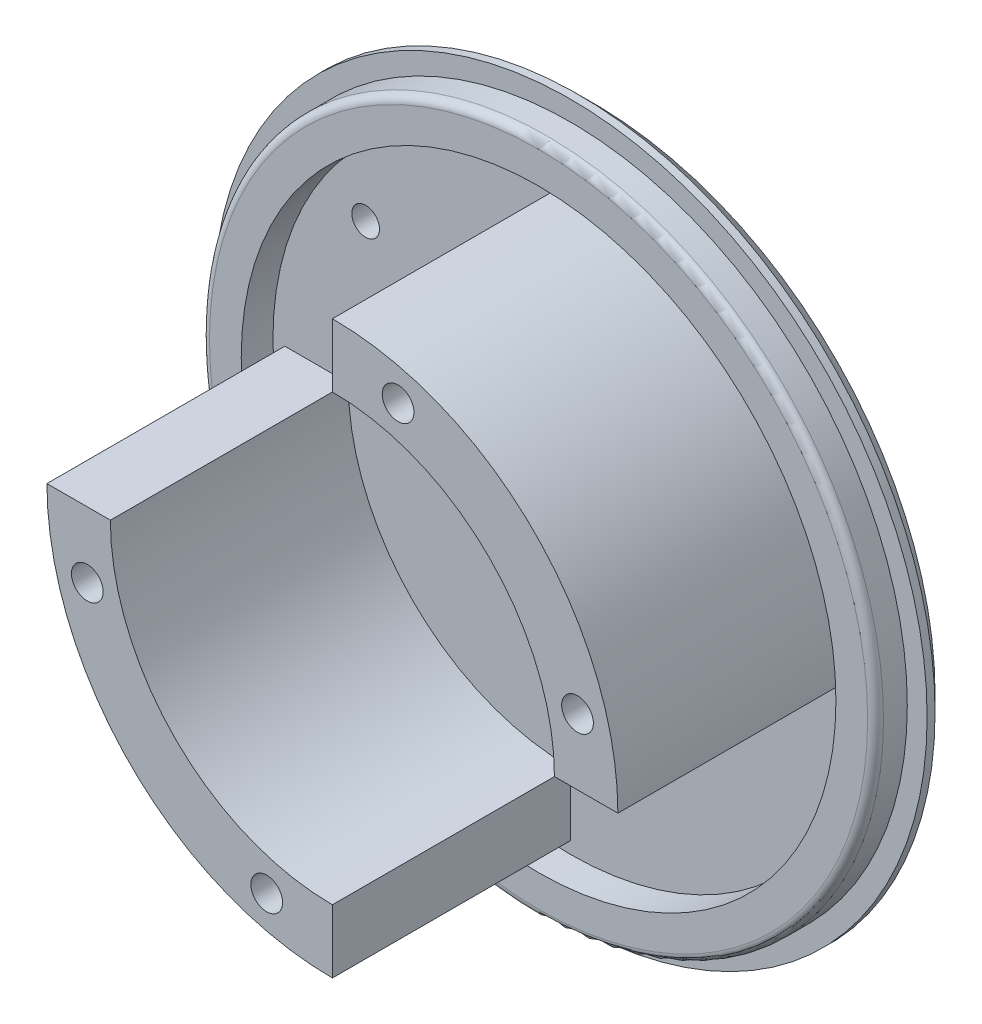
from build123d import *

# Parameters (mm, degrees)
SKETCH1_R           = 45
BOSS_EXTRUDE1_DEPTH = 3
SKETCH2_R           = 42.5
SKETCH2_R_2         = 37.5
BOSS_EXTRUDE2_DEPTH = 4
CHAMFER1_SIZE       = 2
FILLET1_R           = 1
BOSS_EXTRUDE3_DEPTH = 30
SKETCH4_R           = 2
CUT_EXTRUDE1_DEPTH  = 15
CIRPATTERN1_COUNT   = 2
SKETCH5_R           = 1.75
CUT_EXTRUDE2_DEPTH  = 4


with BuildPart() as part:
    # Sketch1 → Boss-Extrude1 (new body)
    with BuildSketch(Plane.XY):
        Circle(SKETCH1_R)
    extrude(amount=BOSS_EXTRUDE1_DEPTH)

    # Sketch2 → Boss-Extrude2 (add)
    with BuildSketch(Plane.XY.offset(3)):
        Circle(SKETCH2_R)
        Circle(SKETCH2_R_2, mode=Mode.SUBTRACT)
    extrude(amount=BOSS_EXTRUDE2_DEPTH)

    # Chamfer1
    chamfer1_edges = [part.edges().sort_by_distance(p)[0] for p in [
        (-45, 0, 0),
    ]]
    chamfer(chamfer1_edges, length=CHAMFER1_SIZE)

    # Fillet1
    fillet1_edges = [part.edges().sort_by_distance(p)[0] for p in [
        (-42.5, 0, 7),
    ]]
    fillet(fillet1_edges, radius=FILLET1_R)

    # Sketch3 → Boss-Extrude3 (add)
    with BuildSketch(Plane.XY.offset(3)):
        with BuildLine():
            Line((-36, 0), (-28, 0))
            ThreePointArc((-28, 0), (-19.798989873, -19.798989873), (0, -28))
            Line((0, -28), (0, -36))
            ThreePointArc((0, -36), (-25.455844123, -25.455844123), (-36, 0))
        make_face()
    boss_extrude3 = extrude(amount=BOSS_EXTRUDE3_DEPTH)

    # Sketch4 → Cut-Extrude1 (cut)
    with BuildSketch(Plane.XY.offset(33)):
        with Locations((-30.909626441, -8.282209443)):
            Circle(SKETCH4_R)
        with Locations((-8.282209443, -30.909626441)):
            Circle(SKETCH4_R)
    cut_extrude1 = extrude(amount=-CUT_EXTRUDE1_DEPTH, mode=Mode.SUBTRACT)

    # CirPattern1: Boss-Extrude3, Cut-Extrude1 ×2 about axis
    cirpattern1_axis = Axis((0, 0, 0), (0, 0, 1))
    for i in range(1, CIRPATTERN1_COUNT):
        add(boss_extrude3.rotate(cirpattern1_axis, i * 360 / CIRPATTERN1_COUNT))
        add(cut_extrude1.rotate(cirpattern1_axis, i * 360 / CIRPATTERN1_COUNT), mode=Mode.SUBTRACT)

    # Sketch5 → Cut-Extrude2 (cut, through all)
    with BuildSketch(Plane.XY.offset(3)):
        with Locations((-25.809397513, 18.738329701)):
            Circle(SKETCH5_R)
        with Locations((-13.788582233, 6.717514421)):
            Circle(SKETCH5_R)
    extrude(amount=-CUT_EXTRUDE2_DEPTH, mode=Mode.SUBTRACT)


solid = part.part
